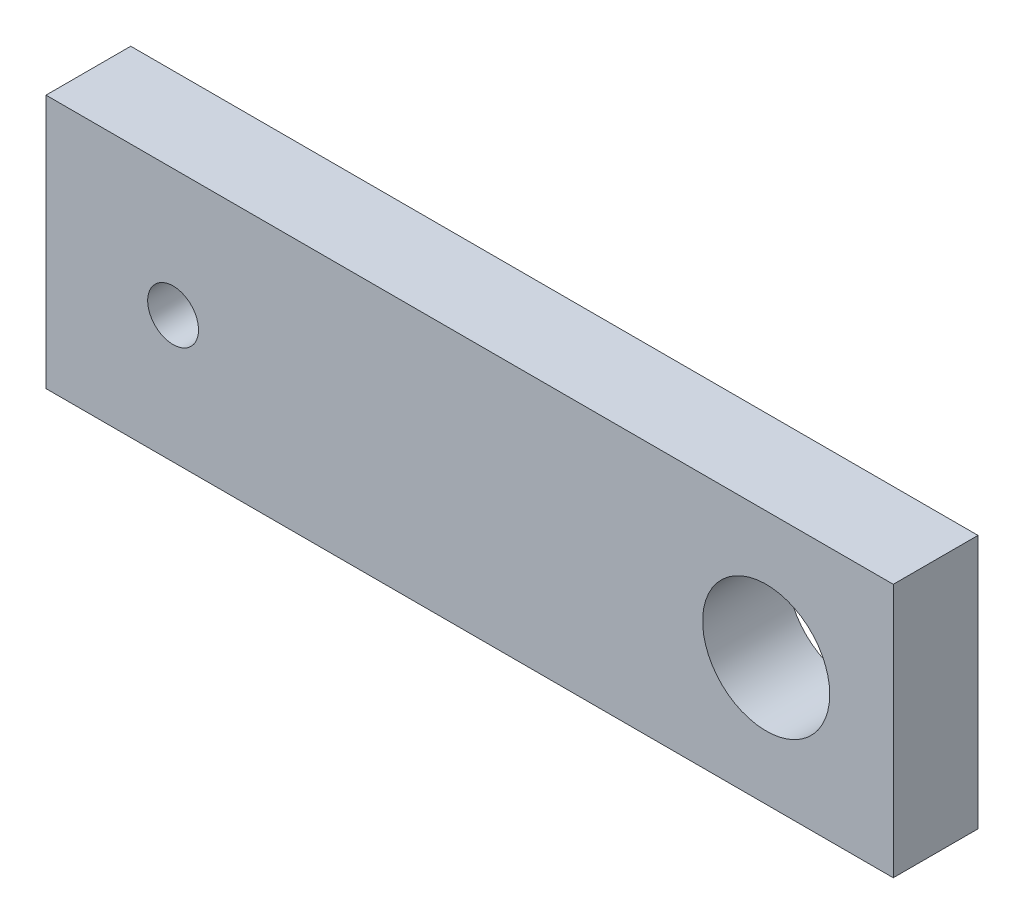
from build123d import *

# Parameters (mm, degrees)
SKETCH1_W           = 20
SKETCH1_H           = 6
SKETCH1_R           = 0.6
SKETCH1_R_2         = 1.5
BOSS_EXTRUDE1_DEPTH = 2


with BuildPart() as part:
    # Sketch1 → Boss-Extrude1 (new body)
    with BuildSketch(Plane.XY):
        with Locations((-10, 3)):
            Rectangle(SKETCH1_W, SKETCH1_H)
        with Locations((-17, 3)):
            Circle(SKETCH1_R, mode=Mode.SUBTRACT)
        with Locations((-3, 3)):
            Circle(SKETCH1_R_2, mode=Mode.SUBTRACT)
    extrude(amount=BOSS_EXTRUDE1_DEPTH)


solid = part.part
